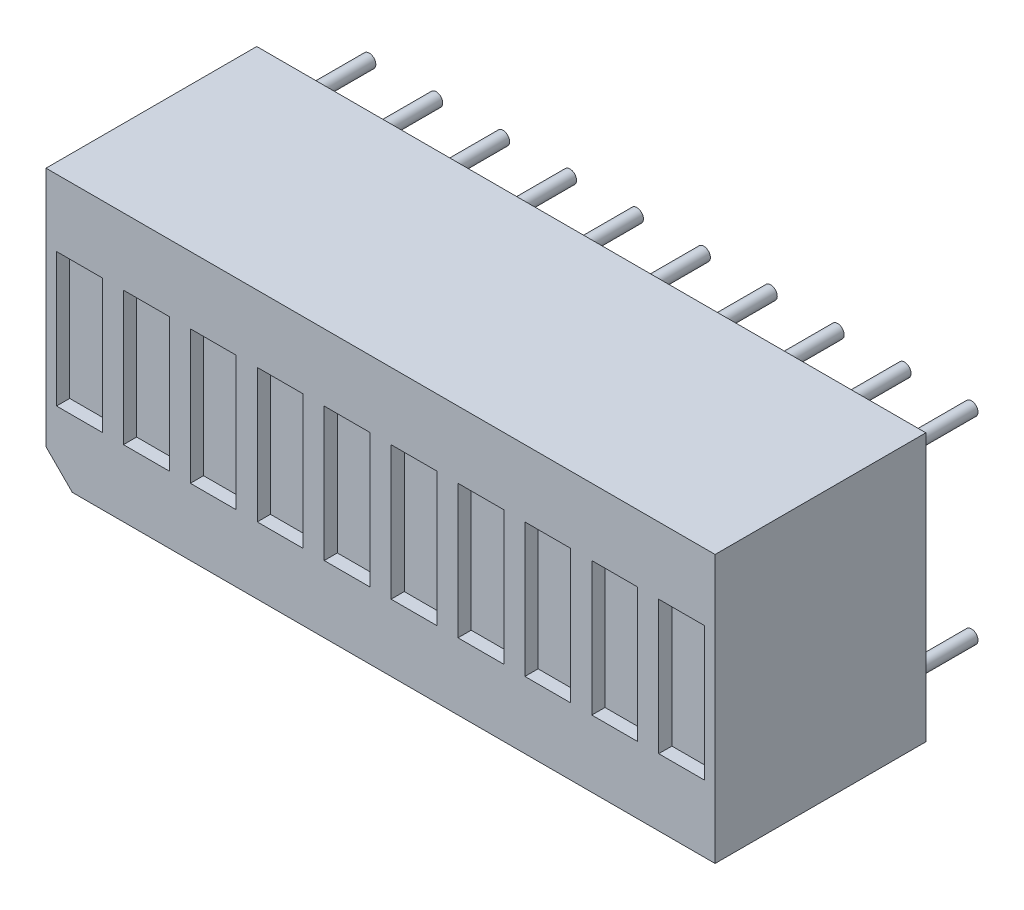
from build123d import *

# Parameters (mm, degrees)
SALIENTE_EXTRUIR1_DEPTH = 8
CROQUIS3_R              = 0.25
SALIENTE_EXTRUIR2_DEPTH = 3
MATRIZL1_COUNT          = 2
MATRIZL1_PITCH          = 12.7
MATRIZL1_COUNT_DIR2     = 2
MATRIZL1_PITCH_DIR2     = 7.5
CROQUIS4_W              = 1.74
CROQUIS4_H              = 5.08
CORTAR_EXTRUIR1_DEPTH   = 0.5
MATRIZL2_COUNT          = 10
MATRIZL2_PITCH          = 2.54


with BuildPart() as part:
    # Croquis1 → Saliente-Extruir1 (new body)
    with BuildSketch(Plane.XY):
        Polygon((-11.7, -5.08), (-12.7, -4.08), (-12.7, 5.08), (12.7, 5.08), (12.7, -5.08), align=None)
    extrude(amount=SALIENTE_EXTRUIR1_DEPTH)

    # Croquis3 → Saliente-Extruir2 (add)
    with BuildSketch(Plane(origin=(0, 0, 0), x_dir=(-1, 0, 0), z_dir=(0, 0, -1))):
        with Locations((-11.43, 3.75)):
            Circle(CROQUIS3_R)
        with Locations((-8.89, 3.75)):
            Circle(CROQUIS3_R)
        with Locations((-6.35, 3.75)):
            Circle(CROQUIS3_R)
        with Locations((-3.81, 3.75)):
            Circle(CROQUIS3_R)
        with Locations((-1.27, 3.75)):
            Circle(CROQUIS3_R)
    saliente_extruir2 = extrude(amount=SALIENTE_EXTRUIR2_DEPTH)

    # MatrizL1: Saliente-Extruir2 2 × 2
    with Locations(*[(-i * MATRIZL1_PITCH, -j * MATRIZL1_PITCH_DIR2, 0) for i in range(MATRIZL1_COUNT) for j in range(MATRIZL1_COUNT_DIR2) if (i, j) != (0, 0)]):
        add(saliente_extruir2)

    # Croquis4 → Cortar-Extruir1 (cut)
    with BuildSketch(Plane.XY.offset(8)):
        with Locations((11.43, 0)):
            Rectangle(CROQUIS4_W, CROQUIS4_H)
    cortar_extruir1 = extrude(amount=-CORTAR_EXTRUIR1_DEPTH, mode=Mode.SUBTRACT)

    # MatrizL2: Cortar-Extruir1 ×10
    with Locations(*[(-i * MATRIZL2_PITCH, 0, 0) for i in range(1, MATRIZL2_COUNT)]):
        add(cortar_extruir1, mode=Mode.SUBTRACT)


solid = part.part
